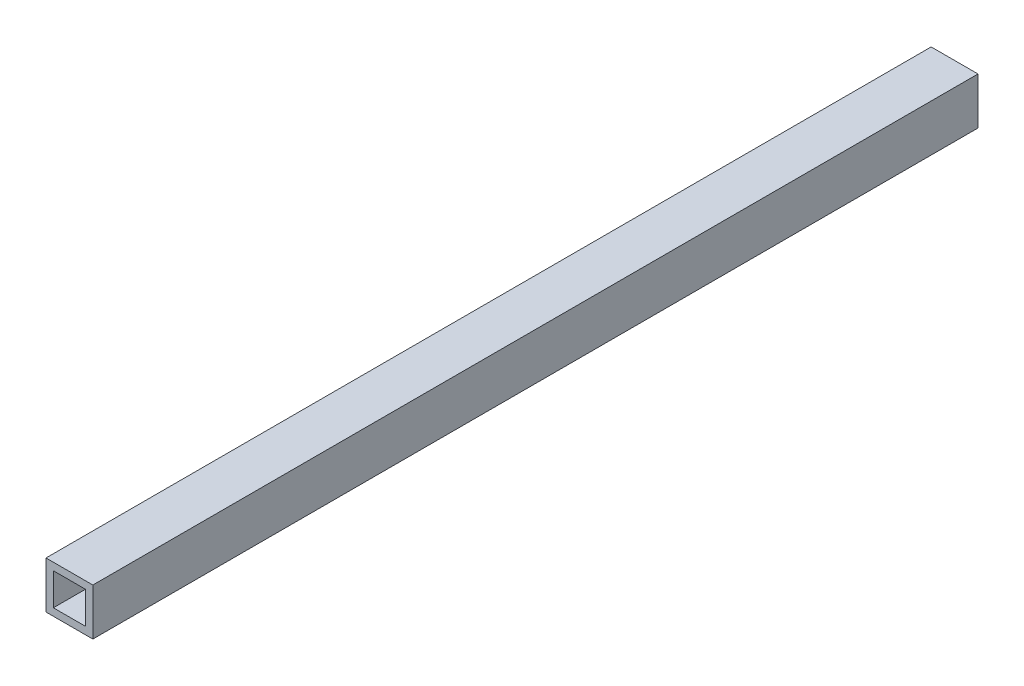
from build123d import *

# Parameters (mm, degrees)
SKETCH1_W           = 12.7
SKETCH1_H           = 12.7
SKETCH1_W_2         = 8.7
SKETCH1_H_2         = 8.7
BOSS_EXTRUDE1_DEPTH = 240


with BuildPart() as part:
    # Sketch1 → Boss-Extrude1 (new body)
    with BuildSketch(Plane.XY):
        Rectangle(SKETCH1_W, SKETCH1_H)
        Rectangle(SKETCH1_W_2, SKETCH1_H_2, mode=Mode.SUBTRACT)
    extrude(amount=BOSS_EXTRUDE1_DEPTH)


solid = part.part
